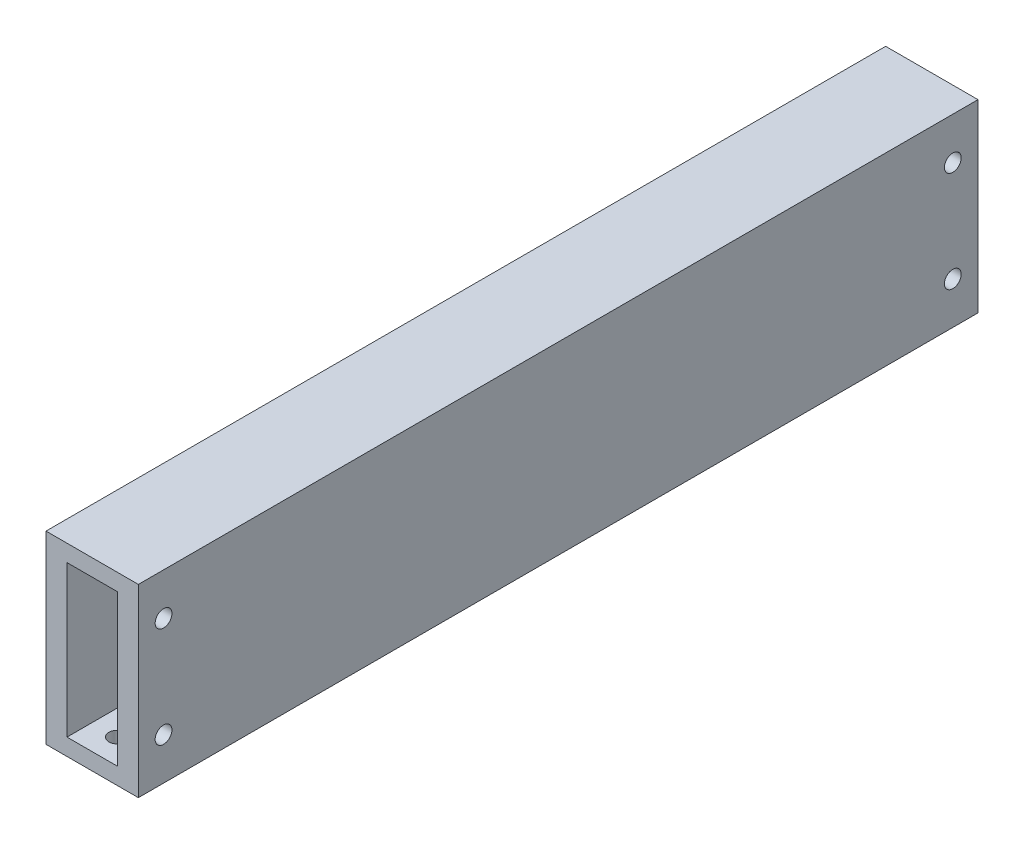
from build123d import *

# Parameters (mm, degrees)
SKETCH1_W                                  = 55
SKETCH1_H                                  = 500
BOSS_EXTRUDE1_DEPTH                        = 110
SKETCH2_W                                  = 15
SKETCH2_H                                  = 45
CUT_EXTRUDE1_DEPTH                         = 500
M10X1_0_TAPPED_HOLE1_D                     = 9
M10X1_0_TAPPED_HOLE1_DEPTH                 = 23
M10X1_0_TAPPED_HOLE1_CBORE_D               = 10
M10X1_0_TAPPED_HOLE1_CBORE_DEPTH           = 20
M10X1_0_TAPPED_HOLE1_TIP                   = 2.703872786
M10X1_0_TAPPED_HOLE2_D                     = 9
M10X1_0_TAPPED_HOLE2_DEPTH                 = 23
M10X1_0_TAPPED_HOLE2_CBORE_D               = 10
M10X1_0_TAPPED_HOLE2_CBORE_DEPTH           = 20
M10X1_0_TAPPED_HOLE2_TIP                   = 2.703872786
M10X1_0_TAPPED_HOLE2_ON_FACE_2_D           = 9
M10X1_0_TAPPED_HOLE2_ON_FACE_2_DEPTH       = 23
M10X1_0_TAPPED_HOLE2_ON_FACE_2_CBORE_D     = 10
M10X1_0_TAPPED_HOLE2_ON_FACE_2_CBORE_DEPTH = 20
M10X1_0_TAPPED_HOLE2_ON_FACE_2_TIP         = 2.703872786


with BuildPart() as part:
    # Sketch1 → Boss-Extrude1 (new body)
    with BuildSketch(Plane(origin=(0, 0, 0), x_dir=(1, 0, 0), z_dir=(0, 1, 0))):
        with Locations((24.098703387, 215.534456811)):
            Rectangle(SKETCH1_W, SKETCH1_H)
    extrude(amount=BOSS_EXTRUDE1_DEPTH)

    # Sketch2 → Cut-Extrude1 (cut)
    with BuildSketch(Plane.XY.offset(34.465543189)):
        with Locations((16.598703387, 77.5)):
            Rectangle(SKETCH2_W, SKETCH2_H)
        with Locations((31.598703387, 77.5)):
            Rectangle(SKETCH2_W, SKETCH2_H)
        with Locations((31.598703387, 32.5)):
            Rectangle(SKETCH2_W, SKETCH2_H)
        with Locations((16.598703387, 32.5)):
            Rectangle(SKETCH2_W, SKETCH2_H)
    extrude(amount=-CUT_EXTRUDE1_DEPTH, mode=Mode.SUBTRACT)

    # M10x1.0 Tapped Hole1
    with Locations(Plane(origin=(0, 10, 0), x_dir=(1, 0, 0), z_dir=(0, 1, 0))):
        with Locations((24.098703387, 450.534456811), (24.098703387, -19.465543189)):
            CounterBoreHole(M10X1_0_TAPPED_HOLE1_D / 2, M10X1_0_TAPPED_HOLE1_CBORE_D / 2, M10X1_0_TAPPED_HOLE1_CBORE_DEPTH, depth=M10X1_0_TAPPED_HOLE1_DEPTH)
            with Locations((0, 0, -(M10X1_0_TAPPED_HOLE1_DEPTH + M10X1_0_TAPPED_HOLE1_TIP / 2))):  # 118° drill point
                Cone(0, M10X1_0_TAPPED_HOLE1_D / 2, M10X1_0_TAPPED_HOLE1_TIP, mode=Mode.SUBTRACT)

    # M10x1.0 Tapped Hole2
    with Locations(Plane(origin=(51.598703387, 85, -450.534456811), x_dir=(0, 0, 1), z_dir=(1, 0, 0))):
        with Locations((0, 0), (0, 60), (470, 0), (470, 60)):
            CounterBoreHole(M10X1_0_TAPPED_HOLE2_D / 2, M10X1_0_TAPPED_HOLE2_CBORE_D / 2, M10X1_0_TAPPED_HOLE2_CBORE_DEPTH, depth=M10X1_0_TAPPED_HOLE2_DEPTH)
            with Locations((0, 0, -(M10X1_0_TAPPED_HOLE2_DEPTH + M10X1_0_TAPPED_HOLE2_TIP / 2))):  # 118° drill point
                Cone(0, M10X1_0_TAPPED_HOLE2_D / 2, M10X1_0_TAPPED_HOLE2_TIP, mode=Mode.SUBTRACT)

    # M10x1.0 Tapped Hole2 on face 2
    with Locations(Plane(origin=(233.947763792, 74.109982143, 0), x_dir=(0, 0, 1), z_dir=(1, 0, 0))):
        with Locations((0, 0)):
            CounterBoreHole(M10X1_0_TAPPED_HOLE2_ON_FACE_2_D / 2, M10X1_0_TAPPED_HOLE2_ON_FACE_2_CBORE_D / 2, M10X1_0_TAPPED_HOLE2_ON_FACE_2_CBORE_DEPTH, depth=M10X1_0_TAPPED_HOLE2_ON_FACE_2_DEPTH)
            with Locations((0, 0, -(M10X1_0_TAPPED_HOLE2_ON_FACE_2_DEPTH + M10X1_0_TAPPED_HOLE2_ON_FACE_2_TIP / 2))):  # 118° drill point
                Cone(0, M10X1_0_TAPPED_HOLE2_ON_FACE_2_D / 2, M10X1_0_TAPPED_HOLE2_ON_FACE_2_TIP, mode=Mode.SUBTRACT)


solid = part.part
